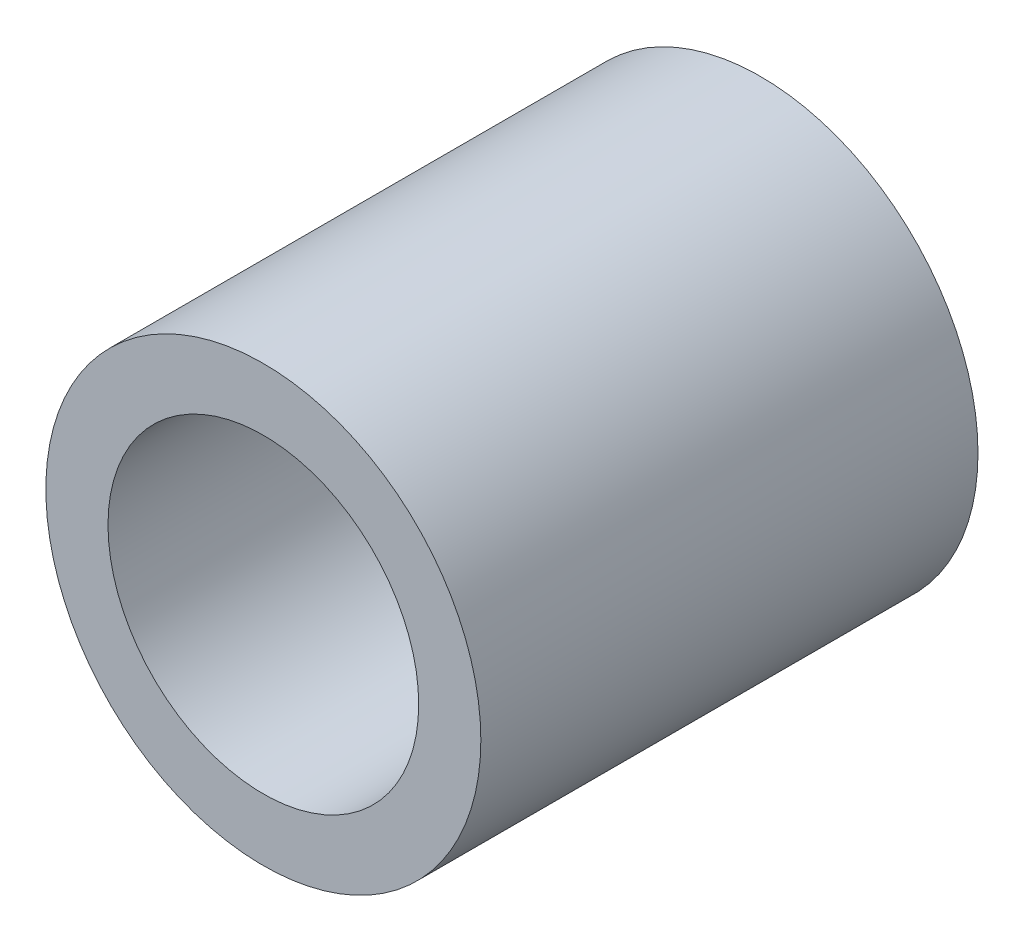
from build123d import *

# Parameters (mm, degrees)
SKETCH1_R           = 3.5
SKETCH1_R_2         = 2.5
BOSS_EXTRUDE1_DEPTH = 8


with BuildPart() as part:
    # Sketch1 → Boss-Extrude1 (new body)
    with BuildSketch(Plane.XY):
        Circle(SKETCH1_R)
        Circle(SKETCH1_R_2, mode=Mode.SUBTRACT)
    extrude(amount=BOSS_EXTRUDE1_DEPTH)


solid = part.part
